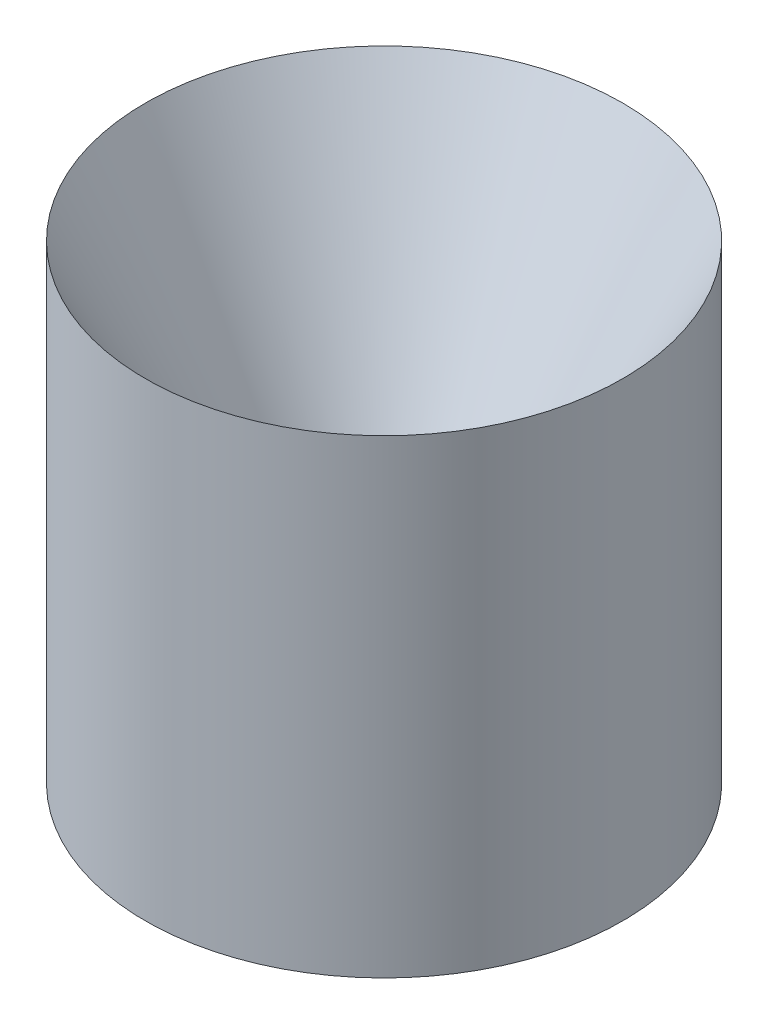
from build123d import *


with BuildPart() as part:
    # Sketch1 → Revolve1 (revolve)
    with BuildSketch(Plane.XY):
        Polygon((-13.335, 0), (-13.335, 15.280189177), (-6.579387507, 15.280189177), (-38.735, 76.2), (-38.735, 0), align=None)
    revolve(axis=Axis((-1.07e-07, 0, 0), (0, 1, 0)))


solid = part.part
